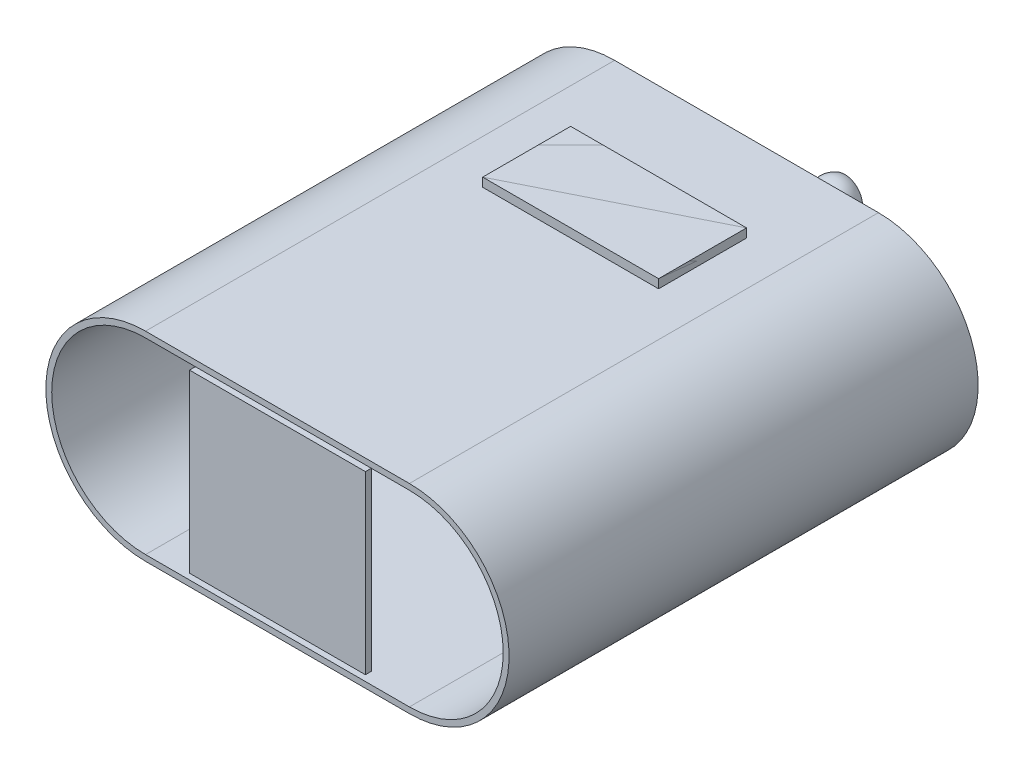
from build123d import *

# Parameters (mm, degrees)
SKETCH1_W           = 45
SKETCH1_H           = 34
BOSS_EXTRUDE1_DEPTH = 80
SHELL1_T            = -1
SKETCH2_W           = 30
SKETCH2_H           = 15
BOSS_EXTRUDE2_DEPTH = 1.5
SKETCH3_W           = 30
SKETCH3_H           = 15
BOSS_EXTRUDE3_DEPTH = 1.5
SKETCH4_W           = 30
SKETCH4_H           = 15
BOSS_EXTRUDE4_DEPTH = 1.5
SKETCH5_W           = 45
SKETCH5_H           = 32
BOSS_EXTRUDE5_DEPTH = 1
SKETCH6_R           = 1.25
BOSS_EXTRUDE6_DEPTH = 15
SKETCH9_R           = 3.5
CUT_EXTRUDE1_DEPTH  = 2.75
SKETCH10_W          = 45
SKETCH10_H          = 32
BOSS_EXTRUDE7_DEPTH = 1
SKETCH11_W          = 30
SKETCH11_H          = 30
BOSS_EXTRUDE8_DEPTH = 1


with BuildPart() as part:
    # Sketch1 → Boss-Extrude1 (new body)
    with BuildSketch(Plane.XY):
        with BuildLine():
            Line((-22.5, -17), (-22.5, 17))
            ThreePointArc((-22.5, 17), (-39.5, 0), (-22.5, -17))
        make_face()
        Rectangle(SKETCH1_W, SKETCH1_H)
        with BuildLine():
            ThreePointArc((22.5, 17), (39.5, 0), (22.5, -17))
            Line((22.5, -17), (22.5, 17))
        make_face()
    extrude(amount=BOSS_EXTRUDE1_DEPTH)

    # Shell1
    shell1_openings = [part.faces().sort_by_distance(p)[0] for p in [
        (0, 0, 80),
    ]]
    offset(amount=SHELL1_T, openings=shell1_openings, kind=Kind.INTERSECTION)

    # Sketch2 → Boss-Extrude2 (add)
    with BuildSketch(Plane.XZ.offset(17)):
        with Locations((0, 22.5)):
            Rectangle(SKETCH2_W, SKETCH2_H)
    boss_extrude2 = extrude(amount=BOSS_EXTRUDE2_DEPTH)

    # Mirror1: Boss-Extrude2 across plane
    add(boss_extrude2.mirror(Plane.ZX))



with BuildPart() as body_2:
    # Sketch3 → Boss-Extrude3 (new body)
    with BuildSketch(Plane(origin=(0, 18.5, 0), x_dir=(1, 0, 0), z_dir=(0, 1, 0))):
        with Locations((0, -22.5)):
            Rectangle(SKETCH3_W, SKETCH3_H)
    extrude(amount=-BOSS_EXTRUDE3_DEPTH)


with BuildPart() as body_3:
    # Sketch4 → Boss-Extrude4 (new body)
    with BuildSketch(Plane.XZ.offset(18.5)):
        with Locations((0, 22.5)):
            Rectangle(SKETCH4_W, SKETCH4_H)
    extrude(amount=-BOSS_EXTRUDE4_DEPTH)


with BuildPart() as body_4:
    # Sketch5 → Boss-Extrude5 (new body)
    with BuildSketch(Plane(origin=(0, 0, 0), x_dir=(-1, 0, 0), z_dir=(0, 0, -1))):
        Rectangle(SKETCH5_W, SKETCH5_H)
    extrude(amount=-BOSS_EXTRUDE5_DEPTH)


with BuildPart() as part_1:
    add(part.part)

    add(body_4.part)  # Boss-Extrude6 merges body 4
    # Sketch6 → Boss-Extrude6 (add)
    with BuildSketch(Plane(origin=(0, 0, 0), x_dir=(-1, 0, 0), z_dir=(0, 0, -1))):
        Circle(SKETCH6_R)
    extrude(amount=BOSS_EXTRUDE6_DEPTH)

    # Sketch7 → Revolve1 (revolve)
    with BuildSketch(Plane(origin=(0, 0, -15), x_dir=(-1, 0, 0), z_dir=(0, 0, -1))):
        with BuildLine():
            Line((-3.5, 0), (3.5, 0))
            ThreePointArc((3.5, 0), (0, 3.5), (-3.5, 0))
        make_face()
    revolve(axis=Axis((3.5, 0, -15), (-1, 0, 0)))

    # Sketch8 → Cut-Revolve1 (revolve, cut)
    with BuildSketch(Plane(origin=(0, 0, -15), x_dir=(-1, 0, 0), z_dir=(0, 0, -1))):
        with BuildLine():
            Line((0, 2.499980539), (0, -2.499980539))
            ThreePointArc((0, -2.499980539), (2.499980539, 0), (0, 2.499980539))
        make_face()
    revolve(axis=Axis((0, 2.499980539, -15), (0, -1, 0)), mode=Mode.SUBTRACT)

    # Sketch9 → Cut-Extrude1 (cut, through all)
    with BuildSketch(Plane(origin=(0, 0, -16.75), x_dir=(-1, 0, 0), z_dir=(0, 0, -1))):
        Circle(SKETCH9_R)
    extrude(amount=CUT_EXTRUDE1_DEPTH, mode=Mode.SUBTRACT)


with BuildPart() as body_4_2:
    # Sketch10 → Boss-Extrude7 (new body)
    with BuildSketch(Plane(origin=(0, 0, 0), x_dir=(-1, 0, 0), z_dir=(0, 0, -1))):
        Rectangle(SKETCH10_W, SKETCH10_H)
    extrude(amount=-BOSS_EXTRUDE7_DEPTH)


with BuildPart() as body_5:
    # Sketch11 → Boss-Extrude8 (new body)
    with BuildSketch(Plane.XY.offset(80)):
        Rectangle(SKETCH11_W, SKETCH11_H)
    extrude(amount=-BOSS_EXTRUDE8_DEPTH)


solid = Compound([body_2.part, body_3.part, part_1.part, body_4_2.part, body_5.part])
